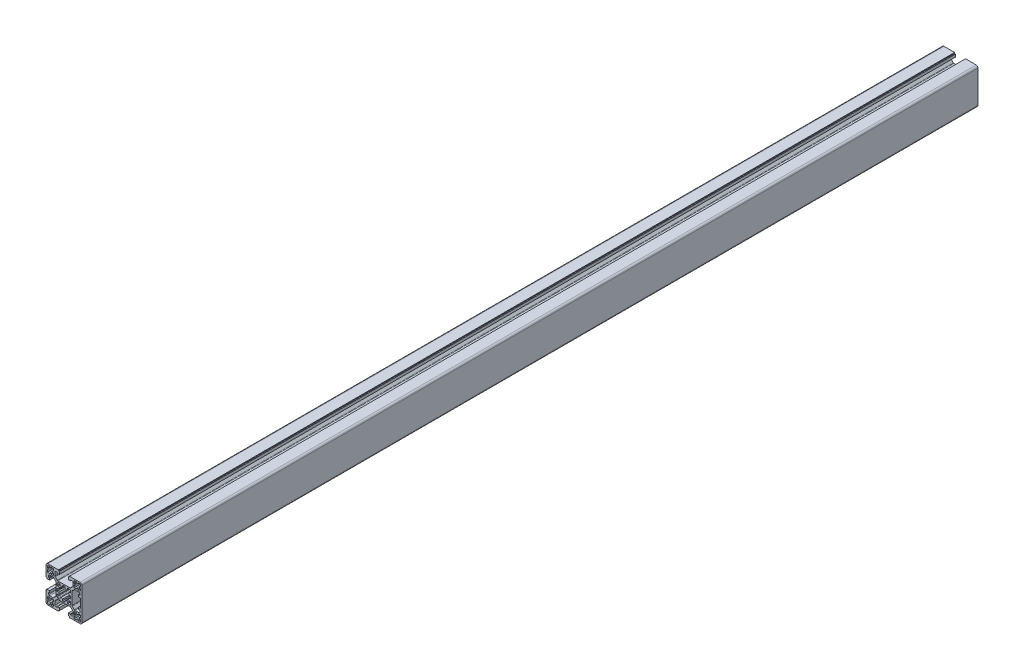
from build123d import *

# Parameters (mm, degrees)
EXTRUDE_1_DEPTH = 1000


with BuildPart() as part:
    # 草图1 → 拉伸1 (new body)
    with BuildSketch(Plane.XY):
        with BuildLine():
            Line((1019.942134338, 688.355300335), (1019.942134338, 689.355300335))
            Line((1019.942134338, 689.355300335), (1021.942134338, 689.355300335))
            Line((1021.942134338, 689.355300335), (1021.942134338, 686.355300335))
            Line((1021.942134338, 686.355300335), (1020.942134338, 686.355300335))
            Line((1020.942134338, 686.355300335), (1020.942134338, 685.355300335))
            Line((1020.942134338, 685.355300335), (1009.042134338, 685.355300335))
            ThreePointArc((1009.042134338, 685.355300335), (1007.627920775, 685.941086772), (1007.042134338, 687.355300335))
            Line((1007.042134338, 687.355300335), (1007.042134338, 699.255300335))
            Line((1007.042134338, 699.255300335), (1008.042134338, 699.255300335))
            Line((1008.042134338, 699.255300335), (1008.042134338, 700.255300335))
            Line((1008.042134338, 700.255300335), (1011.042134338, 700.255300335))
            Line((1011.042134338, 700.255300335), (1011.042134338, 698.255300335))
            Line((1011.042134338, 698.255300335), (1010.042134338, 698.255300335))
            Line((1010.042134338, 698.255300335), (1010.042134338, 696.355300335))
            ThreePointArc((1010.042134338, 696.355300335), (1010.335027557, 695.648193553), (1011.042134338, 695.355300335))
            Line((1011.042134338, 695.355300335), (1014.860153822, 695.355300335))
            ThreePointArc((1014.860153822, 695.355300335), (1015.242837255, 695.431420802), (1015.567260604, 695.648193553))
            Line((1015.567260604, 695.648193553), (1017.749241119, 697.830174069))
            ThreePointArc((1017.749241119, 697.830174069), (1017.96601387, 698.154597418), (1018.042134338, 698.53728085))
            Line((1018.042134338, 698.53728085), (1018.042134338, 712.173319819))
            ThreePointArc((1018.042134338, 712.173319819), (1017.96601387, 712.556003252), (1017.749241119, 712.8804266))
            Line((1017.749241119, 712.8804266), (1015.567260604, 715.062407116))
            ThreePointArc((1015.567260604, 715.062407116), (1015.242837255, 715.279179867), (1014.860153822, 715.355300335))
            Line((1014.860153822, 715.355300335), (1011.042134338, 715.355300335))
            ThreePointArc((1011.042134338, 715.355300335), (1010.335027557, 715.062407116), (1010.042134338, 714.355300335))
            Line((1010.042134338, 714.355300335), (1010.042134338, 712.455300335))
            Line((1010.042134338, 712.455300335), (1011.042134338, 712.455300335))
            Line((1011.042134338, 712.455300335), (1011.042134338, 710.455300335))
            Line((1011.042134338, 710.455300335), (1008.042134338, 710.455300335))
            Line((1008.042134338, 710.455300335), (1008.042134338, 711.455300335))
            Line((1008.042134338, 711.455300335), (1007.042134338, 711.455300335))
            Line((1007.042134338, 711.455300335), (1007.042134338, 723.355300335))
            ThreePointArc((1007.042134338, 723.355300335), (1007.627920775, 724.769513897), (1009.042134338, 725.355300335))
            Line((1009.042134338, 725.355300335), (1020.942134338, 725.355300335))
            Line((1020.942134338, 725.355300335), (1020.942134338, 724.355300335))
            Line((1020.942134338, 724.355300335), (1021.942134338, 724.355300335))
            Line((1021.942134338, 724.355300335), (1021.942134338, 721.355300335))
            Line((1021.942134338, 721.355300335), (1019.942134338, 721.355300335))
            Line((1019.942134338, 721.355300335), (1019.942134338, 722.355300335))
            Line((1019.942134338, 722.355300335), (1018.042134338, 722.355300335))
            ThreePointArc((1018.042134338, 722.355300335), (1017.335027557, 722.062407116), (1017.042134338, 721.355300335))
            Line((1017.042134338, 721.355300335), (1017.042134338, 717.53728085))
            ThreePointArc((1017.042134338, 717.53728085), (1017.118254805, 717.154597418), (1017.335027557, 716.830174069))
            Line((1017.335027557, 716.830174069), (1019.517008072, 714.648193553))
            ThreePointArc((1019.517008072, 714.648193553), (1019.841431421, 714.431420802), (1020.224114853, 714.355300335))
            Line((1020.224114853, 714.355300335), (1033.860153822, 714.355300335))
            ThreePointArc((1033.860153822, 714.355300335), (1034.242837255, 714.431420802), (1034.567260604, 714.648193553))
            Line((1034.567260604, 714.648193553), (1036.749241119, 716.830174069))
            ThreePointArc((1036.749241119, 716.830174069), (1036.96601387, 717.154597418), (1037.042134338, 717.53728085))
            Line((1037.042134338, 717.53728085), (1037.042134338, 721.355300335))
            ThreePointArc((1037.042134338, 721.355300335), (1036.749241119, 722.062407116), (1036.042134338, 722.355300335))
            Line((1036.042134338, 722.355300335), (1034.142134338, 722.355300335))
            Line((1034.142134338, 722.355300335), (1034.142134338, 721.355300335))
            Line((1034.142134338, 721.355300335), (1032.142134338, 721.355300335))
            Line((1032.142134338, 721.355300335), (1032.142134338, 724.355300335))
            Line((1032.142134338, 724.355300335), (1033.142134338, 724.355300335))
            Line((1033.142134338, 724.355300335), (1033.142134338, 725.355300335))
            Line((1033.142134338, 725.355300335), (1045.042134338, 725.355300335))
            ThreePointArc((1045.042134338, 725.355300335), (1046.4563479, 724.769513897), (1047.042134338, 723.355300335))
            Line((1047.042134338, 723.355300335), (1047.042134338, 687.355300335))
            ThreePointArc((1047.042134338, 687.355300335), (1046.4563479, 685.941086772), (1045.042134338, 685.355300335))
            Line((1045.042134338, 685.355300335), (1033.142134338, 685.355300335))
            Line((1033.142134338, 685.355300335), (1033.142134338, 686.355300335))
            Line((1033.142134338, 686.355300335), (1032.142134338, 686.355300335))
            Line((1032.142134338, 686.355300335), (1032.142134338, 689.355300335))
            Line((1032.142134338, 689.355300335), (1034.142134338, 689.355300335))
            Line((1034.142134338, 689.355300335), (1034.142134338, 688.355300335))
            Line((1034.142134338, 688.355300335), (1036.042134338, 688.355300335))
            ThreePointArc((1036.042134338, 688.355300335), (1036.749241119, 688.648193553), (1037.042134338, 689.355300335))
            Line((1037.042134338, 689.355300335), (1037.042134338, 693.173319819))
            ThreePointArc((1037.042134338, 693.173319819), (1036.96601387, 693.556003252), (1036.749241119, 693.8804266))
            Line((1036.749241119, 693.8804266), (1034.567260604, 696.062407116))
            ThreePointArc((1034.567260604, 696.062407116), (1034.242837255, 696.279179867), (1033.860153822, 696.355300335))
            Line((1033.860153822, 696.355300335), (1020.224114853, 696.355300335))
            ThreePointArc((1020.224114853, 696.355300335), (1019.841431421, 696.279179867), (1019.517008072, 696.062407116))
            Line((1019.517008072, 696.062407116), (1017.335027557, 693.8804266))
            ThreePointArc((1017.335027557, 693.8804266), (1017.118254805, 693.556003252), (1017.042134338, 693.173319819))
            Line((1017.042134338, 693.173319819), (1017.042134338, 689.355300335))
            ThreePointArc((1017.042134338, 689.355300335), (1017.335027557, 688.648193553), (1018.042134338, 688.355300335))
            Line((1018.042134338, 688.355300335), (1019.942134338, 688.355300335))
        make_face()
        with BuildLine():
            Line((1011.242134338, 717.855300335), (1012.842134338, 717.855300335))
            Line((1012.842134338, 717.855300335), (1012.842134338, 716.855300335))
            Line((1012.842134338, 716.855300335), (1015.542134338, 716.855300335))
            Line((1015.542134338, 716.855300335), (1015.542134338, 719.555300335))
            Line((1015.542134338, 719.555300335), (1014.542134338, 719.555300335))
            Line((1014.542134338, 719.555300335), (1014.542134338, 721.155300335))
            Line((1014.542134338, 721.155300335), (1015.542134338, 721.155300335))
            Line((1015.542134338, 721.155300335), (1015.542134338, 723.855300335))
            Line((1015.542134338, 723.855300335), (1012.842134338, 723.855300335))
            Line((1012.842134338, 723.855300335), (1012.842134338, 722.855300335))
            Line((1012.842134338, 722.855300335), (1011.242134338, 722.855300335))
            Line((1011.242134338, 722.855300335), (1011.242134338, 723.855300335))
            Line((1011.242134338, 723.855300335), (1009.542134338, 723.855300335))
            ThreePointArc((1009.542134338, 723.855300335), (1008.835027557, 723.562407116), (1008.542134338, 722.855300335))
            Line((1008.542134338, 722.855300335), (1008.542134338, 721.155300335))
            Line((1008.542134338, 721.155300335), (1009.542134338, 721.155300335))
            Line((1009.542134338, 721.155300335), (1009.542134338, 719.555300335))
            Line((1009.542134338, 719.555300335), (1008.542134338, 719.555300335))
            Line((1008.542134338, 719.555300335), (1008.542134338, 716.855300335))
            Line((1008.542134338, 716.855300335), (1011.242134338, 716.855300335))
            Line((1011.242134338, 716.855300335), (1011.242134338, 717.855300335))
        make_face(mode=Mode.SUBTRACT)
        with BuildLine():
            Line((1015.542134338, 689.555300335), (1014.542134338, 689.555300335))
            Line((1014.542134338, 689.555300335), (1014.542134338, 691.155300335))
            Line((1014.542134338, 691.155300335), (1015.542134338, 691.155300335))
            Line((1015.542134338, 691.155300335), (1015.542134338, 693.855300335))
            Line((1015.542134338, 693.855300335), (1012.842134338, 693.855300335))
            Line((1012.842134338, 693.855300335), (1012.842134338, 692.855300335))
            Line((1012.842134338, 692.855300335), (1011.242134338, 692.855300335))
            Line((1011.242134338, 692.855300335), (1011.242134338, 693.855300335))
            Line((1011.242134338, 693.855300335), (1008.542134338, 693.855300335))
            Line((1008.542134338, 693.855300335), (1008.542134338, 691.155300335))
            Line((1008.542134338, 691.155300335), (1009.542134338, 691.155300335))
            Line((1009.542134338, 691.155300335), (1009.542134338, 689.555300335))
            Line((1009.542134338, 689.555300335), (1008.542134338, 689.555300335))
            Line((1008.542134338, 689.555300335), (1008.542134338, 687.855300335))
            ThreePointArc((1008.542134338, 687.855300335), (1008.835027557, 687.148193553), (1009.542134338, 686.855300335))
            Line((1009.542134338, 686.855300335), (1011.242134338, 686.855300335))
            Line((1011.242134338, 686.855300335), (1011.242134338, 687.855300335))
            Line((1011.242134338, 687.855300335), (1012.842134338, 687.855300335))
            Line((1012.842134338, 687.855300335), (1012.842134338, 686.855300335))
            Line((1012.842134338, 686.855300335), (1015.542134338, 686.855300335))
            Line((1015.542134338, 686.855300335), (1015.542134338, 689.555300335))
        make_face(mode=Mode.SUBTRACT)
        with BuildLine():
            Line((1042.842134338, 693.855300335), (1042.842134338, 692.855300335))
            Line((1042.842134338, 692.855300335), (1041.242134338, 692.855300335))
            Line((1041.242134338, 692.855300335), (1041.242134338, 693.855300335))
            Line((1041.242134338, 693.855300335), (1038.542134338, 693.855300335))
            Line((1038.542134338, 693.855300335), (1038.542134338, 691.155300335))
            Line((1038.542134338, 691.155300335), (1039.542134338, 691.155300335))
            Line((1039.542134338, 691.155300335), (1039.542134338, 689.555300335))
            Line((1039.542134338, 689.555300335), (1038.542134338, 689.555300335))
            Line((1038.542134338, 689.555300335), (1038.542134338, 686.855300335))
            Line((1038.542134338, 686.855300335), (1041.242134338, 686.855300335))
            Line((1041.242134338, 686.855300335), (1041.242134338, 687.855300335))
            Line((1041.242134338, 687.855300335), (1042.842134338, 687.855300335))
            Line((1042.842134338, 687.855300335), (1042.842134338, 686.855300335))
            Line((1042.842134338, 686.855300335), (1044.542134338, 686.855300335))
            ThreePointArc((1044.542134338, 686.855300335), (1045.249241119, 687.148193553), (1045.542134338, 687.855300335))
            Line((1045.542134338, 687.855300335), (1045.542134338, 689.555300335))
            Line((1045.542134338, 689.555300335), (1044.542134338, 689.555300335))
            Line((1044.542134338, 689.555300335), (1044.542134338, 691.155300335))
            Line((1044.542134338, 691.155300335), (1045.542134338, 691.155300335))
            Line((1045.542134338, 691.155300335), (1045.542134338, 693.855300335))
            Line((1045.542134338, 693.855300335), (1042.842134338, 693.855300335))
        make_face(mode=Mode.SUBTRACT)
        with BuildLine():
            Line((1025.642134338, 697.855300335), (1028.442134338, 697.855300335))
            Line((1028.442134338, 697.855300335), (1028.442134338, 699.520919476))
            ThreePointArc((1028.442134338, 699.520919476), (1029.338234932, 699.81202314), (1030.177715113, 700.239820572))
            Line((1030.177715113, 700.239820572), (1031.242134338, 699.175401347))
            Line((1031.242134338, 699.175401347), (1031.242134338, 697.855300335))
            Line((1031.242134338, 697.855300335), (1033.542134338, 697.855300335))
            ThreePointArc((1033.542134338, 697.855300335), (1034.249241119, 698.148193553), (1034.542134338, 698.855300335))
            Line((1034.542134338, 698.855300335), (1034.542134338, 701.155300335))
            Line((1034.542134338, 701.155300335), (1033.222033325, 701.155300335))
            Line((1033.222033325, 701.155300335), (1032.1576141, 702.219719559))
            ThreePointArc((1032.1576141, 702.219719559), (1032.585411533, 703.05919974), (1032.876515196, 703.955300335))
            Line((1032.876515196, 703.955300335), (1034.542134338, 703.955300335))
            Line((1034.542134338, 703.955300335), (1034.542134338, 706.755300335))
            Line((1034.542134338, 706.755300335), (1032.876515196, 706.755300335))
            ThreePointArc((1032.876515196, 706.755300335), (1032.585411533, 707.651400929), (1032.1576141, 708.49088111))
            Line((1032.1576141, 708.49088111), (1033.222033325, 709.555300335))
            Line((1033.222033325, 709.555300335), (1034.542134338, 709.555300335))
            Line((1034.542134338, 709.555300335), (1034.542134338, 711.855300335))
            ThreePointArc((1034.542134338, 711.855300335), (1034.249241119, 712.562407116), (1033.542134338, 712.855300335))
            Line((1033.542134338, 712.855300335), (1031.242134338, 712.855300335))
            Line((1031.242134338, 712.855300335), (1031.242134338, 711.535199322))
            Line((1031.242134338, 711.535199322), (1030.177715113, 710.470780097))
            ThreePointArc((1030.177715113, 710.470780097), (1029.338234932, 710.89857753), (1028.442134338, 711.189681193))
            Line((1028.442134338, 711.189681193), (1028.442134338, 712.855300335))
            Line((1028.442134338, 712.855300335), (1025.642134338, 712.855300335))
            Line((1025.642134338, 712.855300335), (1025.642134338, 711.189681193))
            ThreePointArc((1025.642134338, 711.189681193), (1024.746033744, 710.89857753), (1023.906553562, 710.470780097))
            Line((1023.906553562, 710.470780097), (1022.842134338, 711.535199322))
            Line((1022.842134338, 711.535199322), (1022.842134338, 712.855300335))
            Line((1022.842134338, 712.855300335), (1020.542134338, 712.855300335))
            ThreePointArc((1020.542134338, 712.855300335), (1019.835027557, 712.562407116), (1019.542134338, 711.855300335))
            Line((1019.542134338, 711.855300335), (1019.542134338, 709.555300335))
            Line((1019.542134338, 709.555300335), (1020.86223535, 709.555300335))
            Line((1020.86223535, 709.555300335), (1021.926654575, 708.49088111))
            ThreePointArc((1021.926654575, 708.49088111), (1021.498857143, 707.651400929), (1021.207753479, 706.755300335))
            Line((1021.207753479, 706.755300335), (1019.542134338, 706.755300335))
            Line((1019.542134338, 706.755300335), (1019.542134338, 703.955300335))
            Line((1019.542134338, 703.955300335), (1021.207753479, 703.955300335))
            ThreePointArc((1021.207753479, 703.955300335), (1021.498857143, 703.05919974), (1021.926654575, 702.219719559))
            Line((1021.926654575, 702.219719559), (1020.86223535, 701.155300335))
            Line((1020.86223535, 701.155300335), (1019.542134338, 701.155300335))
            Line((1019.542134338, 701.155300335), (1019.542134338, 698.855300335))
            ThreePointArc((1019.542134338, 698.855300335), (1019.835027557, 698.148193553), (1020.542134338, 697.855300335))
            Line((1020.542134338, 697.855300335), (1022.842134338, 697.855300335))
            Line((1022.842134338, 697.855300335), (1022.842134338, 699.175401347))
            Line((1022.842134338, 699.175401347), (1023.906553562, 700.239820572))
            ThreePointArc((1023.906553562, 700.239820572), (1024.746033744, 699.81202314), (1025.642134338, 699.520919476))
            Line((1025.642134338, 699.520919476), (1025.642134338, 697.855300335))
        make_face(mode=Mode.SUBTRACT)
        with BuildLine():
            Line((1043.042134338, 700.255300335), (1045.542134338, 700.255300335))
            Line((1045.542134338, 700.255300335), (1045.542134338, 710.455300335))
            Line((1045.542134338, 710.455300335), (1043.042134338, 710.455300335))
            Line((1043.042134338, 710.455300335), (1043.042134338, 712.455300335))
            Line((1043.042134338, 712.455300335), (1045.042134338, 712.455300335))
            Line((1045.042134338, 712.455300335), (1045.042134338, 714.355300335))
            ThreePointArc((1045.042134338, 714.355300335), (1044.749241119, 715.062407116), (1044.042134338, 715.355300335))
            Line((1044.042134338, 715.355300335), (1039.224114853, 715.355300335))
            ThreePointArc((1039.224114853, 715.355300335), (1038.841431421, 715.279179867), (1038.517008072, 715.062407116))
            Line((1038.517008072, 715.062407116), (1036.335027557, 712.8804266))
            ThreePointArc((1036.335027557, 712.8804266), (1036.118254805, 712.556003252), (1036.042134338, 712.173319819))
            Line((1036.042134338, 712.173319819), (1036.042134338, 698.53728085))
            ThreePointArc((1036.042134338, 698.53728085), (1036.118254805, 698.154597418), (1036.335027557, 697.830174069))
            Line((1036.335027557, 697.830174069), (1038.517008072, 695.648193553))
            ThreePointArc((1038.517008072, 695.648193553), (1038.841431421, 695.431420802), (1039.224114853, 695.355300335))
            Line((1039.224114853, 695.355300335), (1044.042134338, 695.355300335))
            ThreePointArc((1044.042134338, 695.355300335), (1044.749241119, 695.648193553), (1045.042134338, 696.355300335))
            Line((1045.042134338, 696.355300335), (1045.042134338, 698.255300335))
            Line((1045.042134338, 698.255300335), (1043.042134338, 698.255300335))
            Line((1043.042134338, 698.255300335), (1043.042134338, 700.255300335))
        make_face(mode=Mode.SUBTRACT)
        with BuildLine():
            Line((1038.542134338, 721.155300335), (1039.542134338, 721.155300335))
            Line((1039.542134338, 721.155300335), (1039.542134338, 719.555300335))
            Line((1039.542134338, 719.555300335), (1038.542134338, 719.555300335))
            Line((1038.542134338, 719.555300335), (1038.542134338, 716.855300335))
            Line((1038.542134338, 716.855300335), (1041.242134338, 716.855300335))
            Line((1041.242134338, 716.855300335), (1041.242134338, 717.855300335))
            Line((1041.242134338, 717.855300335), (1042.842134338, 717.855300335))
            Line((1042.842134338, 717.855300335), (1042.842134338, 716.855300335))
            Line((1042.842134338, 716.855300335), (1045.542134338, 716.855300335))
            Line((1045.542134338, 716.855300335), (1045.542134338, 719.555300335))
            Line((1045.542134338, 719.555300335), (1044.542134338, 719.555300335))
            Line((1044.542134338, 719.555300335), (1044.542134338, 721.155300335))
            Line((1044.542134338, 721.155300335), (1045.542134338, 721.155300335))
            Line((1045.542134338, 721.155300335), (1045.542134338, 722.855300335))
            ThreePointArc((1045.542134338, 722.855300335), (1045.249241119, 723.562407116), (1044.542134338, 723.855300335))
            Line((1044.542134338, 723.855300335), (1042.842134338, 723.855300335))
            Line((1042.842134338, 723.855300335), (1042.842134338, 722.855300335))
            Line((1042.842134338, 722.855300335), (1041.242134338, 722.855300335))
            Line((1041.242134338, 722.855300335), (1041.242134338, 723.855300335))
            Line((1041.242134338, 723.855300335), (1038.542134338, 723.855300335))
            Line((1038.542134338, 723.855300335), (1038.542134338, 721.155300335))
        make_face(mode=Mode.SUBTRACT)
    extrude(amount=EXTRUDE_1_DEPTH)


solid = part.part
